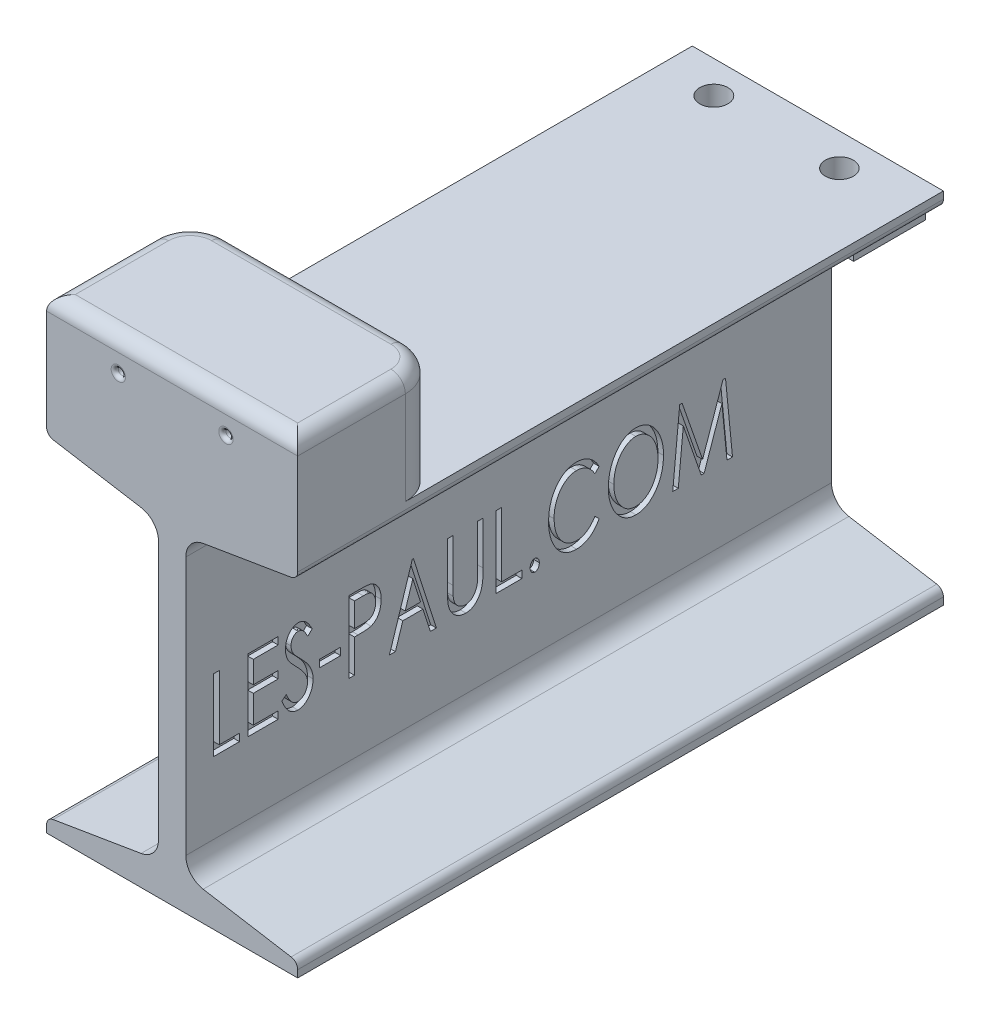
from build123d import *

# Parameters (mm, degrees)
BOSS_EXTRUDE1_DEPTH = 114.3
SKETCH2_W           = 88.9
SKETCH2_H           = 50.8
BOSS_EXTRUDE2_DEPTH = 38.1
FILLET4_R           = 12.7
FILLET5_R           = 5.08
SKETCH42_R          = 1.27
CUT_EXTRUDE3_DEPTH  = 88.9
FILLET8_R           = 1.27
SKETCH45_W          = 76.2
SKETCH45_H          = 25.4
BOSS_EXTRUDE3_DEPTH = 12.065
SKETCH47_R          = 5
CUT_EXTRUDE5_DEPTH  = 12.065
SKETCH47_4_R        = 5
SKETCH47_4_R_2      = 4.953
CUT_EXTRUDE9_DEPTH  = 25.4
SKETCH51_W          = 7.48974359
SKETCH51_H          = 2.605128205
CUT_EXTRUDE8_DEPTH  = 2
SKETCH52_R          = 1.905
CUT_EXTRUDE10_DEPTH = 8.89
SKETCH53_R          = 1.905
CUT_EXTRUDE11_DEPTH = 8.89


with BuildPart() as part:
    # Sketch1 → Boss-Extrude1 (new body, symmetric)
    with BuildSketch(Plane.XY):
        with BuildLine():
            Line((-44.45, 63.5), (44.45, 63.5))
            Line((44.45, 63.5), (44.45, 60.96))
            ThreePointArc((44.45, 60.96), (43.787841232, 59.153985338), (42.11521907, 58.203996762))
            Line((42.11521907, 58.203996762), (10.981331544, 53.016312413))
            ThreePointArc((10.981331544, 53.016312413), (6.571691296, 50.511797077), (4.826, 45.750485695))
            Line((4.826, 45.750485695), (4.826, -45.750485695))
            ThreePointArc((4.826, -45.750485695), (6.571691296, -50.511797077), (10.981331544, -53.016312413))
            Line((10.981331544, -53.016312413), (42.11521907, -58.203996762))
            ThreePointArc((42.11521907, -58.203996762), (43.787841232, -59.153985338), (44.45, -60.96))
            Line((44.45, -60.96), (44.45, -63.5))
            Line((44.45, -63.5), (-44.45, -63.5))
            Line((-44.45, -63.5), (-44.45, -60.96))
            ThreePointArc((-44.45, -60.96), (-43.787841232, -59.153985338), (-42.11521907, -58.203996762))
            Line((-42.11521907, -58.203996762), (-10.981331544, -53.016312413))
            ThreePointArc((-10.981331544, -53.016312413), (-6.571691296, -50.511797077), (-4.826, -45.750485695))
            Line((-4.826, -45.750485695), (-4.826, 45.750485695))
            ThreePointArc((-4.826, 45.750485695), (-6.571691296, 50.511797077), (-10.981331544, 53.016312413))
            Line((-10.981331544, 53.016312413), (-42.11521907, 58.203996762))
            ThreePointArc((-42.11521907, 58.203996762), (-43.787841232, 59.153985338), (-44.45, 60.96))
            Line((-44.45, 60.96), (-44.45, 63.5))
        make_face()
    extrude(amount=BOSS_EXTRUDE1_DEPTH, both=True)

    # Sketch2 → Boss-Extrude2 (add)
    with BuildSketch(Plane(origin=(0, 63.5, 0), x_dir=(1, 0, 0), z_dir=(0, 1, 0))):
        with Locations((0, -88.9)):
            Rectangle(SKETCH2_W, SKETCH2_H)
    extrude(amount=BOSS_EXTRUDE2_DEPTH)

    # Fillet4
    fillet4_edges = [part.edges().sort_by_distance(p)[0] for p in [
        (44.45, 82.55, 63.5),
        (-44.45, 82.55, 63.5),
    ]]
    fillet(fillet4_edges, radius=FILLET4_R)

    # Fillet5
    fillet5_edges = [part.edges().sort_by_distance(p)[0] for p in [
        (0, 101.6, 114.3),
        (44.45, 101.6, 95.25),
        (-44.45, 101.6, 95.25),
        (0, 101.6, 63.5),
        (40.730256121, 101.6, 67.219743879),
        (-40.730256121, 101.6, 67.219743879),
    ]]
    fillet(fillet5_edges, radius=FILLET5_R)

    # Sketch42 → Cut-Extrude3 (cut, symmetric)
    with BuildSketch(Plane(origin=(0, 141.271299333, 63.5), x_dir=(-1, 0, 0), z_dir=(0, 0, 1))):
        with Locations((19.05, 51.101299333)):
            Circle(SKETCH42_R)
        with Locations((-19.05, 51.101299333)):
            Circle(SKETCH42_R)
    extrude(amount=CUT_EXTRUDE3_DEPTH, both=True, mode=Mode.SUBTRACT)

    # Fillet8
    fillet8_edges = [part.edges().sort_by_distance(p)[0] for p in [
        (-17.78, 90.17, 114.3),
        (20.32, 90.17, 114.3),
    ]]
    fillet(fillet8_edges, radius=FILLET8_R)

    # Sketch45 → Boss-Extrude3 (add)
    with BuildSketch(Plane(origin=(0, 63.5, 0), x_dir=(1, 0, 0), z_dir=(0, 1, 0))):
        with Locations((0, 101.6)):
            Rectangle(SKETCH45_W, SKETCH45_H)
    extrude(amount=-BOSS_EXTRUDE3_DEPTH)

    # Sketch47 → Cut-Extrude5 (cut)
    with BuildSketch(Plane(origin=(0, 63.5, 0), x_dir=(1, 0, 0), z_dir=(0, 1, 0))):
        with Locations((-25.4, 102.87)):
            Circle(SKETCH47_R)
    extrude(amount=-CUT_EXTRUDE5_DEPTH, mode=Mode.SUBTRACT)

    # Sketch47_4 → Cut-Extrude9 (cut)
    with BuildSketch(Plane(origin=(0, 63.5, 0), x_dir=(1, 0, 0), z_dir=(0, 1, 0))):
        with Locations((-25.4, 102.87)):
            Circle(SKETCH47_4_R)
        with Locations((19.05, 102.87)):
            Circle(SKETCH47_4_R_2)
    extrude(amount=-CUT_EXTRUDE9_DEPTH, mode=Mode.SUBTRACT)

    # Sketch51 → Cut-Extrude8 (cut)
    with BuildSketch(Plane(origin=(4.826, 0, 0), x_dir=(0, 0, -1), z_dir=(1, 0, 0))):
        Polygon((-104.400512821, 5.049514305), (-102.446666667, 5.049514305), (-102.446666667, -17.74535749), (-95.282564103, -17.74535749), (-95.282564103, -20.350485695), (-104.400512821, -20.350485695), align=None)
        Polygon((-92.351794872, 5.049514305), (-81.605641026, 5.049514305), (-81.605641026, 2.444386099), (-90.397948718, 2.444386099), (-90.397948718, -5.370998516), (-81.605641026, -5.370998516), (-81.605641026, -7.976126721), (-90.397948718, -7.976126721), (-90.397948718, -17.74535749), (-81.605641026, -17.74535749), (-81.605641026, -20.350485695), (-92.351794872, -20.350485695), align=None)
        with BuildLine():
            Line((-80.303076923, -15.450605888), (-78.715576923, -14.163306208))
            add(Edge.make_bspline(
                [(-78.715576923, -14.163306208), (-78.574883617, -14.496433349), (-78.307790261, -15.128844713), (-77.848672791, -15.991031141), (-77.378359146, -16.725351333), (-76.890233935, -17.328288444), (-76.384195686, -17.804340451), (-75.85371575, -18.142323844), (-75.302010403, -18.357564561), (-74.923304676, -18.383738902), (-74.736650641, -18.396639542)],
                knots=[0, 0, 0, 0, 0.001084395, 0.002058624, 0.002926566, 0.003696626, 0.004380825, 0.005000535, 0.005575224, 0.006133762, 0.006133762, 0.006133762, 0.006133762], degree=3))
            add(Edge.make_bspline(
                [(-74.736650641, -18.396639542), (-74.576468371, -18.390537748), (-74.258840481, -18.378438407), (-73.793054903, -18.257490271), (-73.340345311, -18.0751798), (-72.912086788, -17.812424708), (-72.508521276, -17.497580365), (-72.163797993, -17.113149287), (-71.857485983, -16.690314469), (-71.617890012, -16.213746414), (-71.424733171, -15.708929022), (-71.290284342, -15.182736725), (-71.196220604, -14.643254704), (-71.188856966, -14.277354762), (-71.185128205, -14.092072234)],
                knots=[0, 0, 0, 0, 0.00047961, 0.000951025, 0.0014348, 0.001939168, 0.002453297, 0.002964649, 0.003482791, 0.004015298, 0.00455961, 0.005101396, 0.005642607, 0.006197798, 0.006197798, 0.006197798, 0.006197798], degree=3))
            add(Edge.make_bspline(
                [(-71.185128205, -14.092072234), (-71.193674346, -13.881298182), (-71.210894362, -13.456599726), (-71.329186502, -12.824261314), (-71.536991306, -12.200441646), (-71.7284779, -11.802193381), (-71.826233974, -11.598883131)],
                knots=[0, 0, 0, 0, 0.000632241, 0.001273932, 0.001922366, 0.002598649, 0.002598649, 0.002598649, 0.002598649], degree=3))
            add(Edge.make_bspline(
                [(-71.826233974, -11.598883131), (-71.905987395, -11.453745961), (-72.072088808, -11.151470663), (-72.365014851, -10.699407637), (-72.703227769, -10.225743541), (-73.082307628, -9.727923138), (-73.514212659, -9.213847701), (-73.986064705, -8.67474508), (-74.50542128, -8.114957594), (-74.873060772, -7.741135876), (-75.062291667, -7.548722875)],
                knots=[0, 0, 0, 0, 0.000496687, 0.001034444, 0.001614692, 0.002242599, 0.002911007, 0.003628507, 0.004391796, 0.005201386, 0.005201386, 0.005201386, 0.005201386], degree=3))
            add(Edge.make_bspline(
                [(-75.062291667, -7.548722875), (-75.25189093, -7.358349557), (-75.615101585, -6.993656065), (-76.114764574, -6.450539225), (-76.571044501, -5.961384157), (-76.963046142, -5.50541873), (-77.302697139, -5.095265609), (-77.593123878, -4.730360526), (-77.816296476, -4.39919465), (-77.941286482, -4.189343936), (-77.998149038, -4.093875118)],
                knots=[0, 0, 0, 0, 0.000805953, 0.001543944, 0.002213764, 0.002812567, 0.003347427, 0.003811537, 0.004210916, 0.004544257, 0.004544257, 0.004544257, 0.004544257], degree=3))
            add(Edge.make_bspline(
                [(-77.998149038, -4.093875118), (-78.152440258, -3.793914077), (-78.459797177, -3.196374555), (-78.769602487, -2.237298794), (-78.968261992, -1.244297894), (-78.989675656, -0.568765651), (-79.000512821, -0.226887939)],
                knots=[0, 0, 0, 0, 0.001010441, 0.002012857, 0.003012751, 0.004037288, 0.004037288, 0.004037288, 0.004037288], degree=3))
            add(Edge.make_bspline(
                [(-79.000512821, -0.226887939), (-78.994305521, 0.041496069), (-78.982070331, 0.570507014), (-78.866540242, 1.344372237), (-78.683628239, 2.082613124), (-78.431597929, 2.778052601), (-78.111011709, 3.420077948), (-77.733048162, 4.000243636), (-77.281030927, 4.497518939), (-76.786237033, 4.928531811), (-76.241173941, 5.265998963), (-75.672646448, 5.524795485), (-75.072713582, 5.668738171), (-74.66611162, 5.690078118), (-74.461891026, 5.700796356)],
                knots=[0, 0, 0, 0, 0.000804715, 0.001586171, 0.002341413, 0.003083462, 0.00380024, 0.004490317, 0.0051533, 0.005810045, 0.006452401, 0.007069767, 0.007676942, 0.008289635, 0.008289635, 0.008289635, 0.008289635], degree=3))
            add(Edge.make_bspline(
                [(-74.461891026, 5.700796356), (-74.243669026, 5.690417405), (-73.807046608, 5.669651019), (-73.16679994, 5.487783195), (-72.554594587, 5.190244396), (-72.066474848, 4.855743598), (-71.687451483, 4.520671185), (-71.390353168, 4.22049364), (-71.098610553, 3.864313062), (-70.790224847, 3.469964893), (-70.488913429, 3.019190023), (-70.175643019, 2.526339413), (-69.868642719, 1.979242308), (-69.663201287, 1.598355935), (-69.556923077, 1.401317189)],
                knots=[0, 0, 0, 0, 0.000653683, 0.0013079, 0.001979264, 0.002689165, 0.003074959, 0.003495924, 0.003954562, 0.004455273, 0.004997202, 0.005580232, 0.006206921, 0.006878575, 0.006878575, 0.006878575, 0.006878575], degree=3))
            Line((-69.556923077, 1.401317189), (-71.083365385, -0.160742106))
            add(Edge.make_bspline(
                [(-71.083365385, -0.160742106), (-71.168930099, -0.000795523), (-71.332993353, 0.305888801), (-71.584061842, 0.739264255), (-71.820916916, 1.13099335), (-72.05094068, 1.478357018), (-72.269429838, 1.784187514), (-72.477206685, 2.051494102), (-72.678614357, 2.273670301), (-72.927821762, 2.510573967), (-73.240715575, 2.74512807), (-73.639017921, 2.949431668), (-74.057957136, 3.071007308), (-74.34410618, 3.087442087), (-74.487331731, 3.095668151)],
                knots=[0, 0, 0, 0, 0.000544146, 0.001043354, 0.00150236, 0.001917254, 0.002292847, 0.00262978, 0.002932343, 0.003191489, 0.00366062, 0.004099794, 0.004528227, 0.004957565, 0.004957565, 0.004957565, 0.004957565], degree=3))
            add(Edge.make_bspline(
                [(-74.487331731, 3.095668151), (-74.66877358, 3.08647948), (-75.024186363, 3.068480486), (-75.525353653, 2.879242124), (-75.971187528, 2.578372594), (-76.352332198, 2.170810679), (-76.661269865, 1.680842351), (-76.88786195, 1.128659851), (-77.021007222, 0.520540979), (-77.037943899, 0.097723497), (-77.046666667, -0.120036977)],
                knots=[0, 0, 0, 0, 0.000542239, 0.001062152, 0.001582885, 0.002144336, 0.002723065, 0.003311731, 0.003926533, 0.004579423, 0.004579423, 0.004579423, 0.004579423], degree=3))
            add(Edge.make_bspline(
                [(-77.046666667, -0.120036977), (-77.033080223, -0.390714519), (-77.005922293, -0.93177164), (-76.843629942, -1.599403645), (-76.642627053, -2.129342179), (-76.428746008, -2.539066923), (-76.174599595, -2.971704269), (-75.972083393, -3.25420864), (-75.866217949, -3.401887939)],
                knots=[0, 0, 0, 0, 0.000811714, 0.001622534, 0.002047752, 0.002509681, 0.003007071, 0.003551883, 0.003551883, 0.003551883, 0.003551883], degree=3))
            add(Edge.make_bspline(
                [(-75.866217949, -3.401887939), (-75.827835439, -3.451600508), (-75.736576788, -3.569797627), (-75.560941685, -3.758140072), (-75.340211291, -4.003503553), (-75.062080868, -4.292129336), (-74.73700842, -4.63684926), (-74.352902659, -5.021190357), (-73.921179917, -5.459513004), (-73.615645978, -5.767953556), (-73.454439103, -5.930694029)],
                knots=[0, 0, 0, 0, 0.00018833, 0.000447775, 0.000771902, 0.001178604, 0.001650047, 0.002193335, 0.00280858, 0.00349578, 0.00349578, 0.00349578, 0.00349578], degree=3))
            add(Edge.make_bspline(
                [(-73.454439103, -5.930694029), (-73.260089637, -6.131578371), (-72.882087045, -6.522291058), (-72.346688869, -7.108486753), (-71.85668176, -7.67626187), (-71.420196394, -8.232054599), (-71.025925928, -8.766747429), (-70.678124786, -9.284447064), (-70.382162152, -9.78984777), (-70.053120761, -10.432908519), (-69.729533391, -11.231594932), (-69.438239942, -12.192390034), (-69.264617012, -13.159729922), (-69.242344243, -13.806472362), (-69.231282051, -14.127689221)],
                knots=[0, 0, 0, 0, 0.000838494, 0.00163084, 0.002381406, 0.003087852, 0.003750366, 0.004374115, 0.004957922, 0.005506333, 0.006540028, 0.007538134, 0.008514341, 0.009477627, 0.009477627, 0.009477627, 0.009477627], degree=3))
            add(Edge.make_bspline(
                [(-69.231282051, -14.127689221), (-69.236519066, -14.355134053), (-69.24686259, -14.804355837), (-69.318372907, -15.466447204), (-69.440192426, -16.10655258), (-69.61533976, -16.723270673), (-69.831914738, -17.320720737), (-70.103967282, -17.891392682), (-70.421218347, -18.439920118), (-70.782908222, -18.958188131), (-71.181645769, -19.433020967), (-71.603277765, -19.853472645), (-72.048074267, -20.207887604), (-72.516129622, -20.496855874), (-73.005716667, -20.72006243), (-73.515145392, -20.886632907), (-74.047579911, -20.98566503), (-74.4105984, -20.996359421), (-74.594182692, -21.001767747)],
                knots=[0, 0, 0, 0, 0.000682285, 0.001347568, 0.001995203, 0.002634712, 0.003268956, 0.003899414, 0.004528638, 0.005168066, 0.00579283, 0.006386488, 0.006951478, 0.007495148, 0.008032471, 0.008561858, 0.009099783, 0.009650149, 0.009650149, 0.009650149, 0.009650149], degree=3))
            add(Edge.make_bspline(
                [(-74.594182692, -21.001767747), (-74.736927008, -20.998188552), (-75.018662454, -20.99112427), (-75.435138458, -20.924549855), (-75.844486996, -20.832406731), (-76.240788092, -20.685131701), (-76.629712613, -20.509631519), (-77.003879286, -20.285724321), (-77.370555567, -20.026606371), (-77.728699096, -19.724355887), (-78.078039857, -19.374163986), (-78.417305558, -18.971863689), (-78.749091709, -18.515289114), (-79.072739215, -18.005828318), (-79.394201492, -17.444135858), (-79.70824748, -16.829511568), (-80.014319473, -16.160138837), (-80.204760855, -15.692187499), (-80.303076923, -15.450605888)],
                knots=[0, 0, 0, 0, 0.000427888, 0.000844526, 0.0012629, 0.001684571, 0.002110306, 0.002541389, 0.002990329, 0.003456137, 0.003945446, 0.004472505, 0.005033263, 0.005637361, 0.006282352, 0.006974133, 0.007707267, 0.008489667, 0.008489667, 0.008489667, 0.008489667], degree=3))
        make_face()
        with Locations((-63.206923077, -10.581254927)):
            Rectangle(SKETCH51_W, SKETCH51_H)
        with BuildLine():
            Line((-56.531282051, 5.049514305), (-52.898349359, 5.049514305))
            add(Edge.make_bspline(
                [(-52.898349359, 5.049514305), (-52.649010304, 5.049127554), (-52.170591209, 5.048385477), (-51.485311202, 5.026598822), (-50.862648149, 4.997311822), (-50.302851098, 4.95638716), (-49.80483673, 4.909355055), (-49.372443176, 4.841696449), (-49.001690845, 4.770874621), (-48.78154173, 4.700345007), (-48.680280449, 4.667903728)],
                knots=[0, 0, 0, 0, 0.000747974, 0.001435175, 0.002056678, 0.002617852, 0.003119079, 0.0035566, 0.003930812, 0.004249542, 0.004249542, 0.004249542, 0.004249542], degree=3))
            add(Edge.make_bspline(
                [(-48.680280449, 4.667903728), (-48.552015626, 4.619489914), (-48.295211071, 4.522558522), (-47.928952703, 4.332547841), (-47.581014099, 4.108071771), (-47.253706927, 3.845520441), (-46.942665308, 3.548980817), (-46.647057106, 3.218143743), (-46.371717984, 2.850158489), (-46.119477474, 2.447177817), (-45.883247624, 2.018502798), (-45.686874401, 1.554786194), (-45.512275649, 1.070077508), (-45.376565832, 0.553444781), (-45.263270829, 0.013938558), (-45.189048837, -0.555947186), (-45.142117935, -1.15043114), (-45.136639204, -1.556495486), (-45.133846154, -1.763506529)],
                knots=[0, 0, 0, 0, 0.000411007, 0.000822895, 0.001235003, 0.001651392, 0.002079674, 0.002522926, 0.002980859, 0.003456566, 0.003948329, 0.004447408, 0.0049656, 0.005492634, 0.006048454, 0.006618371, 0.007215442, 0.007836383, 0.007836383, 0.007836383, 0.007836383], degree=3))
            add(Edge.make_bspline(
                [(-45.133846154, -1.763506529), (-45.136423039, -1.972237292), (-45.141457617, -2.38004418), (-45.191116525, -2.977368426), (-45.256532579, -3.547823137), (-45.368349611, -4.088343611), (-45.49496568, -4.604263588), (-45.667577355, -5.088122819), (-45.857605826, -5.54782307), (-46.082766424, -5.975678602), (-46.332995003, -6.372297697), (-46.600873169, -6.741611214), (-46.897649176, -7.071856432), (-47.213815104, -7.371041177), (-47.55773514, -7.629204014), (-47.919543148, -7.861569976), (-48.307996904, -8.054695776), (-48.579300656, -8.158112609), (-48.715897436, -8.210181208)],
                knots=[0, 0, 0, 0, 0.000626027, 0.001223099, 0.001797405, 0.002347231, 0.002877887, 0.003389594, 0.003886671, 0.00436916, 0.00483785, 0.005292748, 0.005736, 0.006167983, 0.006596416, 0.007024122, 0.007456464, 0.007894872, 0.007894872, 0.007894872, 0.007894872], degree=3))
            add(Edge.make_bspline(
                [(-48.715897436, -8.210181208), (-48.82913221, -8.243939831), (-49.07534797, -8.317344004), (-49.483687297, -8.401072413), (-49.95596725, -8.470900541), (-50.496043926, -8.525366709), (-51.101804604, -8.569661071), (-51.775192385, -8.606051548), (-52.51322552, -8.625824368), (-53.027237781, -8.626865806), (-53.295224359, -8.627408772)],
                knots=[0, 0, 0, 0, 0.000354348, 0.000770488, 0.001249017, 0.001786196, 0.002398487, 0.003071066, 0.003809127, 0.004613069, 0.004613069, 0.004613069, 0.004613069], degree=3))
            Line((-53.295224359, -8.627408772), (-54.577435897, -8.627408772))
            Line((-54.577435897, -8.627408772), (-54.577435897, -20.350485695))
            Line((-54.577435897, -20.350485695), (-56.531282051, -20.350485695))
            Line((-56.531282051, -20.350485695), (-56.531282051, 5.049514305))
        make_face()
        with BuildLine():
            Line((-54.577435897, 2.444386099), (-54.577435897, -6.022280567))
            Line((-54.577435897, -6.022280567), (-51.570344551, -6.078250118))
            add(Edge.make_bspline(
                [(-51.570344551, -6.078250118), (-51.286835731, -6.07287522), (-50.75732528, -6.062836501), (-50.02432771, -5.978938482), (-49.408784403, -5.844701497), (-48.902832856, -5.636755027), (-48.486281899, -5.355830012), (-48.12896026, -5.005818034), (-47.819613843, -4.585188594), (-47.556903748, -4.099998762), (-47.344961094, -3.567366829), (-47.199301739, -2.994111282), (-47.104239547, -2.394219645), (-47.093265093, -1.982667415), (-47.087692308, -1.773682811)],
                knots=[0, 0, 0, 0, 0.000850268, 0.001588048, 0.002210072, 0.002734546, 0.003218588, 0.00370795, 0.004227962, 0.00477901, 0.005359148, 0.005942888, 0.006550234, 0.00717682, 0.00717682, 0.00717682, 0.00717682], degree=3))
            add(Edge.make_bspline(
                [(-47.087692308, -1.773682811), (-47.093294555, -1.569771147), (-47.104370282, -1.166634755), (-47.200069973, -0.577127952), (-47.34436422, -0.010121912), (-47.559264266, 0.516679765), (-47.811539713, 0.999318299), (-48.115349707, 1.412647557), (-48.45590874, 1.753512646), (-48.852959605, 2.022896919), (-49.33464404, 2.221342853), (-49.92646237, 2.348278921), (-50.639986668, 2.436475154), (-51.157863687, 2.441608684), (-51.438052885, 2.444386099)],
                knots=[0, 0, 0, 0, 0.00061134, 0.001208628, 0.001787447, 0.002362857, 0.00291148, 0.003417258, 0.003895787, 0.004350201, 0.004847279, 0.005448326, 0.006160847, 0.007000776, 0.007000776, 0.007000776, 0.007000776], degree=3))
            Line((-51.438052885, 2.444386099), (-54.577435897, 2.444386099))
        make_face(mode=Mode.SUBTRACT)
        Polygon((-33.736410256, 5.049514305), (-25.595384615, -20.350485695), (-27.722227564, -20.350485695), (-30.33244391, -12.209460054), (-37.466017628, -12.209460054), (-40.076233974, -20.350485695), (-42.203076923, -20.350485695), (-34.062051282, 5.049514305), align=None)
        Polygon((-33.90431891, -1.07660749), (-36.6315625, -9.604331849), (-31.166899038, -9.604331849), align=None, mode=Mode.SUBTRACT)
        with BuildLine():
            Line((-21.687692308, 5.049514305), (-19.733846154, 5.049514305))
            Line((-19.733846154, 5.049514305), (-19.733846154, -10.169115503))
            add(Edge.make_bspline(
                [(-19.733846154, -10.169115503), (-19.734419854, -10.384516578), (-19.73550855, -10.793277238), (-19.728236791, -11.374997759), (-19.725702189, -11.89235871), (-19.714004206, -12.346852391), (-19.704025682, -12.736958287), (-19.694984171, -13.064383663), (-19.682065003, -13.327637009), (-19.66489684, -13.481545667), (-19.657524038, -13.547641144)],
                knots=[0, 0, 0, 0, 0.000646194, 0.001226264, 0.00174528, 0.002198239, 0.002590158, 0.002915957, 0.003180981, 0.003380459, 0.003380459, 0.003380459, 0.003380459], degree=3))
            add(Edge.make_bspline(
                [(-19.657524038, -13.547641144), (-19.628500308, -13.785528724), (-19.572401982, -14.245328173), (-19.439416747, -14.902992696), (-19.247868487, -15.498207989), (-19.017901644, -16.041506813), (-18.713443662, -16.528228893), (-18.352378106, -16.976137824), (-17.910560553, -17.374210295), (-17.416863421, -17.729748591), (-16.884655689, -18.020840242), (-16.342600981, -18.238509636), (-15.795470228, -18.373915672), (-15.428316153, -18.389102605), (-15.246105769, -18.396639542)],
                knots=[0, 0, 0, 0, 0.00071887, 0.001389463, 0.002008985, 0.00259226, 0.003154263, 0.003725632, 0.004312624, 0.0049325, 0.005547303, 0.00612744, 0.006681581, 0.007227531, 0.007227531, 0.007227531, 0.007227531], degree=3))
            add(Edge.make_bspline(
                [(-15.246105769, -18.396639542), (-15.08962082, -18.389043265), (-14.77878863, -18.373954482), (-14.316590866, -18.274558358), (-13.869052874, -18.102389717), (-13.428355626, -17.875103887), (-13.017408151, -17.578544882), (-12.628794838, -17.238033747), (-12.290631999, -16.8342915), (-11.977105905, -16.390448523), (-11.700348353, -15.893297698), (-11.471044736, -15.34409019), (-11.272560598, -14.747796334), (-11.181788637, -14.328876041), (-11.134887821, -14.112424798)],
                knots=[0, 0, 0, 0, 0.000469462, 0.000932511, 0.001410715, 0.001904579, 0.002415627, 0.002927333, 0.003450522, 0.003991159, 0.004556035, 0.005153323, 0.005774409, 0.006438387, 0.006438387, 0.006438387, 0.006438387], degree=3))
            add(Edge.make_bspline(
                [(-11.134887821, -14.112424798), (-11.118829001, -14.022660899), (-11.082910338, -13.821886536), (-11.043103257, -13.485669778), (-11.017354938, -13.08635569), (-10.982523165, -12.625430568), (-10.966224461, -12.100974039), (-10.94844737, -11.512501877), (-10.947256666, -10.861088123), (-10.943500587, -10.406556715), (-10.941538462, -10.169115503)],
                knots=[0, 0, 0, 0, 0.000273532, 0.000611807, 0.001014928, 0.001473877, 0.001998351, 0.002588773, 0.003240074, 0.003952432, 0.003952432, 0.003952432, 0.003952432], degree=3))
            Line((-10.941538462, -10.169115503), (-10.941538462, 5.049514305))
            Line((-10.941538462, 5.049514305), (-8.987692308, 5.049514305))
            Line((-8.987692308, 5.049514305), (-8.987692308, -10.291230888))
            add(Edge.make_bspline(
                [(-8.987692308, -10.291230888), (-8.990533503, -10.567689397), (-8.996077146, -11.107105631), (-9.013427966, -11.897839266), (-9.055248583, -12.647631356), (-9.110508473, -13.356854675), (-9.18120725, -14.023757316), (-9.267674915, -14.651616557), (-9.368044959, -15.239108412), (-9.52083616, -15.961557271), (-9.776619791, -16.81273591), (-10.218639971, -17.768322022), (-10.79046292, -18.655096676), (-11.360184996, -19.331391117), (-11.873854095, -19.814309761), (-12.282598124, -20.131452442), (-12.709738156, -20.401659521), (-13.157032622, -20.625112237), (-13.626448525, -20.789923549), (-14.114452866, -20.915562923), (-14.623304788, -20.985867639), (-14.96945034, -20.996430688), (-15.144342949, -21.001767747)],
                knots=[0, 0, 0, 0, 0.000829429, 0.001618354, 0.002372498, 0.003081961, 0.003752303, 0.004384093, 0.004983026, 0.005539893, 0.006598936, 0.007641595, 0.008687452, 0.009755913, 0.010285105, 0.010800089, 0.011305457, 0.011799242, 0.012296554, 0.012795114, 0.013308891, 0.013833586, 0.013833586, 0.013833586, 0.013833586], degree=3))
            add(Edge.make_bspline(
                [(-15.144342949, -21.001767747), (-15.334444779, -20.996045068), (-15.708998608, -20.984769788), (-16.261665501, -20.920457578), (-16.789998131, -20.800724473), (-17.30120776, -20.644562733), (-17.787408934, -20.432366142), (-18.26038219, -20.186471825), (-18.702238532, -19.879117375), (-19.130351055, -19.542682642), (-19.525278722, -19.160658417), (-19.887265534, -18.745553018), (-20.220658136, -18.304732909), (-20.508203878, -17.827370218), (-20.770980402, -17.325568616), (-20.999288128, -16.793878471), (-21.18794843, -16.229645739), (-21.286497992, -15.841385898), (-21.336610577, -15.643955247)],
                knots=[0, 0, 0, 0, 0.000570439, 0.001123925, 0.001665878, 0.002193722, 0.002724866, 0.00325523, 0.003790091, 0.004336799, 0.004887378, 0.005435435, 0.005988008, 0.006543012, 0.00710513, 0.007686382, 0.008276892, 0.008887829, 0.008887829, 0.008887829, 0.008887829], degree=3))
            add(Edge.make_bspline(
                [(-21.336610577, -15.643955247), (-21.3651897, -15.508533148), (-21.427406906, -15.213717078), (-21.495101418, -14.729190151), (-21.554953912, -14.170876531), (-21.607119698, -13.538155706), (-21.63776502, -12.83201936), (-21.672113064, -12.0520219), (-21.684450758, -11.196956491), (-21.68658149, -10.60160589), (-21.687692308, -10.291230888)],
                knots=[0, 0, 0, 0, 0.000415112, 0.000903707, 0.001466723, 0.0020997, 0.002807848, 0.003586932, 0.004441876, 0.00537302, 0.00537302, 0.00537302, 0.00537302], degree=3))
            Line((-21.687692308, -10.291230888), (-21.687692308, 5.049514305))
        make_face()
        Polygon((-4.428717949, 5.049514305), (-2.474871795, 5.049514305), (-2.474871795, -17.74535749), (4.689230769, -17.74535749), (4.689230769, -20.350485695), (-4.428717949, -20.350485695), align=None)
        with BuildLine():
            add(Edge.make_bspline(
                [(9.248205128, -16.442793388), (9.357685185, -16.45117466), (9.574048565, -16.467738411), (9.885896937, -16.585144278), (10.164862871, -16.786744107), (10.410783294, -17.057131819), (10.615586159, -17.379584969), (10.773485392, -17.740423245), (10.858613205, -18.140026264), (10.870349325, -18.416618454), (10.876410256, -18.559460054)],
                knots=[0, 0, 0, 0, 0.000328175, 0.000648567, 0.000984538, 0.001351802, 0.001738534, 0.002126035, 0.002527257, 0.00295575, 0.00295575, 0.00295575, 0.00295575], degree=3))
            add(Edge.make_bspline(
                [(10.876410256, -18.559460054), (10.870120689, -18.698878826), (10.857798962, -18.972010482), (10.773741068, -19.368467348), (10.614115424, -19.72994497), (10.412429179, -20.055944852), (10.164886383, -20.327492872), (9.884788133, -20.527359019), (9.575215863, -20.652614995), (9.357873824, -20.668241658), (9.248205128, -20.676126721)],
                knots=[0, 0, 0, 0, 0.000418343, 0.000819565, 0.001207066, 0.001598092, 0.001965356, 0.002301327, 0.002623532, 0.002951707, 0.002951707, 0.002951707, 0.002951707], degree=3))
            add(Edge.make_bspline(
                [(9.248205128, -20.676126721), (9.138482352, -20.668317699), (8.921033137, -20.652841734), (8.610958156, -20.525920707), (8.326677342, -20.329449327), (8.079481459, -20.05551119), (7.875882643, -19.731263361), (7.724140643, -19.367124251), (7.638181975, -18.972195679), (7.626144482, -18.698941412), (7.62, -18.559460054)],
                knots=[0, 0, 0, 0, 0.000328175, 0.00065038, 0.000990525, 0.001357788, 0.001748815, 0.00213434, 0.002535562, 0.002953905, 0.002953905, 0.002953905, 0.002953905], degree=3))
            add(Edge.make_bspline(
                [(7.62, -18.559460054), (7.625910501, -18.416553565), (7.637355336, -18.139835727), (7.724396655, -17.741766412), (7.874436941, -17.378278185), (8.081123528, -17.057561776), (8.326698585, -16.784787628), (8.609836957, -16.586554169), (8.922199845, -16.467509752), (9.138670692, -16.451097833), (9.248205128, -16.442793388)],
                knots=[0, 0, 0, 0, 0.000428493, 0.000829715, 0.00121524, 0.001601972, 0.001969236, 0.002309381, 0.002629772, 0.002957947, 0.002957947, 0.002957947, 0.002957947], degree=3))
        make_face()
        with BuildLine():
            Line((32.043076923, 0.388777125), (30.567516026, -1.137665183))
            add(Edge.make_bspline(
                [(30.567516026, -1.137665183), (30.365599146, -0.80756093), (29.973387366, -0.166352643), (29.289404565, 0.696909986), (28.534807974, 1.424690638), (27.727701589, 2.030796204), (26.869652313, 2.509799174), (25.962076402, 2.847381147), (25.014302572, 3.059851564), (24.366179375, 3.083663483), (24.03943109, 3.095668151)],
                knots=[0, 0, 0, 0, 0.001160197, 0.002253614, 0.003293551, 0.004296935, 0.005273977, 0.006230385, 0.007193443, 0.008172602, 0.008172602, 0.008172602, 0.008172602], degree=3))
            add(Edge.make_bspline(
                [(24.03943109, 3.095668151), (23.859381578, 3.092656319), (23.499530748, 3.086636808), (22.967368351, 3.010199005), (22.44419207, 2.900246368), (21.932166349, 2.740122239), (21.43060983, 2.536862782), (20.935877473, 2.290688618), (20.456036098, 1.995283753), (19.986577396, 1.658773597), (19.537166616, 1.283478674), (19.108172471, 0.877651471), (18.711410848, 0.435159739), (18.333029608, -0.030338217), (17.987790284, -0.532392414), (17.664816104, -1.063186423), (17.372898976, -1.627463973), (17.101497705, -2.217201057), (16.864214277, -2.832999668), (16.654244686, -3.467431674), (16.48307755, -4.124432238), (16.333983839, -4.797465832), (16.221854133, -5.490617541), (16.149009463, -6.202633691), (16.0934915, -6.932191906), (16.088955538, -7.426497262), (16.086666667, -7.675926401)],
                knots=[0, 0, 0, 0, 0.000539727, 0.00107871, 0.001609635, 0.002142337, 0.002685625, 0.003231742, 0.003798082, 0.004374189, 0.004963118, 0.005553342, 0.006144093, 0.006744838, 0.007351758, 0.007970443, 0.008607681, 0.009256593, 0.009917072, 0.010586429, 0.011260295, 0.011952918, 0.012653901, 0.013365259, 0.014099715, 0.014847828, 0.014847828, 0.014847828, 0.014847828], degree=3))
            add(Edge.make_bspline(
                [(16.086666667, -7.675926401), (16.09312673, -8.051034849), (16.105781912, -8.785867484), (16.216229041, -9.863709261), (16.389472615, -10.894156547), (16.648950759, -11.875644747), (16.96592045, -12.813482556), (17.359258869, -13.705105036), (17.829326137, -14.544290306), (18.359779926, -15.330986027), (18.946503931, -16.045802891), (19.575661765, -16.675828143), (20.248892722, -17.204003087), (20.953774675, -17.641233133), (21.698789794, -17.981978884), (22.483032105, -18.218142388), (23.303922781, -18.374575872), (23.865698891, -18.389201962), (24.151370192, -18.396639542)],
                knots=[0, 0, 0, 0, 0.001125043, 0.002203945, 0.003247064, 0.004256569, 0.005246144, 0.006214296, 0.007175523, 0.008128107, 0.009057121, 0.0099458, 0.010793705, 0.011618376, 0.012428989, 0.013243378, 0.014070744, 0.014926778, 0.014926778, 0.014926778, 0.014926778], degree=3))
            add(Edge.make_bspline(
                [(24.151370192, -18.396639542), (24.466227146, -18.384325687), (25.0887927, -18.359977546), (25.999699959, -18.153047395), (26.869205667, -17.820016184), (27.696292964, -17.348169859), (28.484260262, -16.747065947), (29.228757213, -16.010927143), (29.935320498, -15.144986371), (30.351659593, -14.498490449), (30.567516026, -14.163306208)],
                knots=[0, 0, 0, 0, 0.000943627, 0.001865831, 0.002787136, 0.003728125, 0.004712191, 0.005752028, 0.006862188, 0.008057479, 0.008057479, 0.008057479, 0.008057479], degree=3))
            Line((30.567516026, -14.163306208), (32.043076923, -15.674484093))
            add(Edge.make_bspline(
                [(32.043076923, -15.674484093), (31.928279739, -15.881010584), (31.700778277, -16.290298311), (31.325270159, -16.87316548), (30.926249659, -17.417584409), (30.51321479, -17.932972787), (30.072467841, -18.406845812), (29.612439519, -18.847360002), (29.132781, -19.252004831), (28.630321206, -19.616185702), (28.111866517, -19.944096928), (27.574723902, -20.223954784), (27.023910946, -20.463848618), (26.458376028, -20.663719749), (25.876358804, -20.817071718), (25.278784812, -20.921648818), (24.666945529, -20.991814844), (24.253331095, -20.998428742), (24.044519231, -21.001767747)],
                knots=[0, 0, 0, 0, 0.000708733, 0.001404544, 0.002078276, 0.002733067, 0.003384766, 0.004018153, 0.004642918, 0.005265773, 0.005878467, 0.006481578, 0.007080878, 0.007679508, 0.008279305, 0.00888413, 0.00949828, 0.010124452, 0.010124452, 0.010124452, 0.010124452], degree=3))
            add(Edge.make_bspline(
                [(24.044519231, -21.001767747), (23.847613776, -20.999803698), (23.456364011, -20.995901146), (22.879120272, -20.935248504), (22.315938594, -20.851797997), (21.771404979, -20.726739109), (21.238748279, -20.577698535), (20.726114791, -20.380294858), (20.225720218, -20.159421041), (19.744658149, -19.895690147), (19.276484963, -19.601309818), (18.823004282, -19.271223748), (18.391200477, -18.901922581), (17.971538322, -18.504506078), (17.569419127, -18.070602846), (17.182761871, -17.601295417), (16.809830393, -17.097393117), (16.57996917, -16.740923554), (16.463189103, -16.559820631)],
                knots=[0, 0, 0, 0, 0.000590422, 0.001173164, 0.001739504, 0.002297462, 0.002848205, 0.003397276, 0.003943867, 0.004488013, 0.005041381, 0.00560214, 0.006168937, 0.006744774, 0.007335218, 0.007942393, 0.008568255, 0.009214589, 0.009214589, 0.009214589, 0.009214589], degree=3))
            add(Edge.make_bspline(
                [(16.463189103, -16.559820631), (16.27627419, -16.242166507), (15.900316683, -15.603242348), (15.432488669, -14.585795333), (15.025385857, -13.524965966), (14.705531584, -12.411728607), (14.439152091, -11.254688265), (14.269876825, -10.045746303), (14.150207125, -8.790937299), (14.138685626, -7.937419698), (14.132820513, -7.502929606)],
                knots=[0, 0, 0, 0, 0.001105076, 0.002222731, 0.003354828, 0.004510855, 0.005694655, 0.006913623, 0.008170301, 0.009473352, 0.009473352, 0.009473352, 0.009473352], degree=3))
            add(Edge.make_bspline(
                [(14.132820513, -7.502929606), (14.141589467, -7.046347891), (14.158806664, -6.149883204), (14.294952637, -4.833994598), (14.509287804, -3.572397878), (14.823670189, -2.369577442), (15.21198823, -1.215613798), (15.703593574, -0.123575767), (16.275469348, 0.918396351), (16.932370598, 1.891514387), (17.651322115, 2.783172241), (18.426795818, 3.564062402), (19.25281889, 4.218535948), (20.115619598, 4.76605291), (21.029310418, 5.187414811), (21.989536999, 5.48187342), (22.992730951, 5.665876389), (23.677383821, 5.689055784), (24.024166667, 5.700796356)],
                knots=[0, 0, 0, 0, 0.001369476, 0.002688865, 0.003964538, 0.005204803, 0.006414819, 0.007612868, 0.008792538, 0.009976545, 0.011130387, 0.012224136, 0.013270674, 0.014285717, 0.015282888, 0.016279086, 0.017292137, 0.018331912, 0.018331912, 0.018331912, 0.018331912], degree=3))
            add(Edge.make_bspline(
                [(24.024166667, 5.700796356), (24.234638082, 5.697223633), (24.653250253, 5.690117749), (25.272644638, 5.622903738), (25.877366935, 5.509006911), (26.465902307, 5.357271412), (27.041246716, 5.165045608), (27.595093377, 4.91745162), (28.135816837, 4.632220346), (28.660480788, 4.307063277), (29.163379151, 3.938863217), (29.648103206, 3.538265325), (30.104531089, 3.097279695), (30.546700996, 2.629866203), (30.955607362, 2.11987507), (31.345407454, 1.576926044), (31.711051889, 0.999363428), (31.931698482, 0.593599485), (32.043076923, 0.388777125)],
                knots=[0, 0, 0, 0, 0.000631258, 0.001255525, 0.001866272, 0.002475915, 0.003077694, 0.003683696, 0.004293679, 0.004910688, 0.005533544, 0.006162212, 0.006795599, 0.007436382, 0.008091172, 0.008754819, 0.009440869, 0.010140169, 0.010140169, 0.010140169, 0.010140169], degree=3))
        make_face()
        with BuildLine():
            add(Edge.make_bspline(
                [(44.946602564, 5.700796356), (45.291614187, 5.68887377), (45.971080431, 5.665393418), (46.969763854, 5.484499457), (47.920366967, 5.173072776), (48.836226709, 4.757116187), (49.698622399, 4.204337883), (50.519011112, 3.53639389), (51.294213608, 2.745987933), (52.018379691, 1.845829141), (52.679457006, 0.862124893), (53.258774379, -0.188238529), (53.745369137, -1.294441702), (54.151237682, -2.455362465), (54.459688317, -3.673100149), (54.676629273, -4.947506169), (54.81159312, -6.275476793), (54.829066804, -7.180356814), (54.837948718, -7.640309413)],
                knots=[0, 0, 0, 0, 0.001034696, 0.002037731, 0.003032147, 0.004029319, 0.005047074, 0.006096021, 0.007196989, 0.00836194, 0.009557231, 0.010748269, 0.011955618, 0.013178572, 0.014433622, 0.015719322, 0.0170539, 0.018433546, 0.018433546, 0.018433546, 0.018433546], degree=3))
            add(Edge.make_bspline(
                [(54.837948718, -7.640309413), (54.829097108, -8.096877511), (54.811684899, -8.995003276), (54.676159649, -10.314418734), (54.459946723, -11.582192844), (54.149642932, -12.797655249), (53.745702696, -13.958363429), (53.26220502, -15.070064986), (52.686173865, -16.126622287), (52.023175386, -17.114549345), (51.305018396, -18.020095341), (50.537778617, -18.815688482), (49.733881399, -19.4951073), (48.880326886, -20.043062725), (47.992330094, -20.477455272), (47.059730262, -20.77639654), (46.092499221, -20.968045054), (45.432576696, -20.990450602), (45.099246795, -21.001767747)],
                knots=[0, 0, 0, 0, 0.001369476, 0.002693928, 0.003974614, 0.005224734, 0.006452495, 0.007657794, 0.008857754, 0.010057272, 0.011223001, 0.012320495, 0.013368059, 0.014372951, 0.015356056, 0.016324702, 0.01730365, 0.018302793, 0.018302793, 0.018302793, 0.018302793], degree=3))
            add(Edge.make_bspline(
                [(45.099246795, -21.001767747), (44.760817057, -20.99065685), (44.094110783, -20.968768393), (43.116895623, -20.775889074), (42.178494071, -20.477410331), (41.281185768, -20.049498493), (40.425739194, -19.499752187), (39.613248006, -18.824886132), (38.839092186, -18.033856907), (38.119521141, -17.129819648), (37.457440744, -16.14815482), (36.880494668, -15.098374762), (36.390923374, -13.999093129), (35.996077243, -12.846714275), (35.675252116, -11.649535669), (35.462302543, -10.397380341), (35.325500754, -9.096869126), (35.308255714, -8.212233088), (35.299487179, -7.762424798)],
                knots=[0, 0, 0, 0, 0.001014379, 0.001998326, 0.002976653, 0.003962151, 0.004971323, 0.006019554, 0.00712415, 0.008285907, 0.009481198, 0.010672236, 0.011874933, 0.013086606, 0.014323233, 0.015588882, 0.016893085, 0.01824222, 0.01824222, 0.01824222, 0.01824222], degree=3))
            add(Edge.make_bspline(
                [(35.299487179, -7.762424798), (35.303327996, -7.460422239), (35.310952809, -6.860884938), (35.374161426, -5.969503474), (35.474640285, -5.093181076), (35.618980639, -4.234684177), (35.793645946, -3.390774728), (36.022164637, -2.567573318), (36.276493064, -1.756225708), (36.586424045, -0.971783806), (36.914596162, -0.20992089), (37.290104558, 0.507054367), (37.685083734, 1.184391571), (38.108170299, 1.820874114), (38.56771407, 2.409301802), (39.051483321, 2.961858068), (39.564883641, 3.472416626), (40.110302289, 3.932982677), (40.669706127, 4.351225591), (41.249415792, 4.707025257), (41.83540877, 5.016837512), (42.43579699, 5.264297099), (43.046053709, 5.461838477), (43.6700959, 5.596250353), (44.304422161, 5.68883286), (44.732571588, 5.696809067), (44.946602564, 5.700796356)],
                knots=[0, 0, 0, 0, 0.000905918, 0.001798433, 0.00267949, 0.003551108, 0.004409331, 0.005263473, 0.006113086, 0.006958774, 0.007792608, 0.008600486, 0.009385001, 0.010144225, 0.010891264, 0.011623126, 0.012346305, 0.013061003, 0.013763185, 0.014439525, 0.015099514, 0.015749622, 0.016385232, 0.017021006, 0.017662878, 0.018304489, 0.018304489, 0.018304489, 0.018304489], degree=3))
        make_face()
        with BuildLine():
            add(Edge.make_bspline(
                [(45.033100962, 3.095668151), (44.863213373, 3.092660404), (44.523599407, 3.086647764), (44.020221721, 3.009863198), (43.522780641, 2.899031914), (43.031150827, 2.741308348), (42.548939561, 2.528825444), (42.068801231, 2.281283675), (41.598944798, 1.982808482), (41.139887253, 1.642628149), (40.691469298, 1.270370936), (40.275309059, 0.85320694), (39.87708564, 0.411848387), (39.505432354, -0.062889552), (39.159122436, -0.567784648), (38.836848516, -1.104138981), (38.543196056, -1.674368536), (38.182734206, -2.477075486), (37.806158396, -3.539265), (37.489260009, -4.881857814), (37.29020473, -6.29450146), (37.265790987, -7.259722884), (37.253333333, -7.752248516)],
                knots=[0, 0, 0, 0, 0.000509221, 0.001017959, 0.001524043, 0.002037341, 0.00256381, 0.003103177, 0.003656546, 0.004231528, 0.004816554, 0.005403016, 0.005997545, 0.006599109, 0.007210215, 0.007833258, 0.00847501, 0.009133192, 0.010472137, 0.011848176, 0.01326575, 0.014742793, 0.014742793, 0.014742793, 0.014742793], degree=3))
            add(Edge.make_bspline(
                [(37.253333333, -7.752248516), (37.259902859, -8.118863478), (37.272797174, -8.838435839), (37.382139528, -9.89452364), (37.559166636, -10.906689603), (37.808768105, -11.876648843), (38.128764246, -12.804745895), (38.521402151, -13.688658051), (38.987492917, -14.527256202), (39.516529278, -15.313958646), (40.095436173, -16.032637821), (40.712439645, -16.661457152), (41.356022133, -17.197996933), (42.033644838, -17.633025416), (42.738307257, -17.981020823), (43.479668548, -18.217174828), (44.246324637, -18.373776692), (44.769436385, -18.388977741), (45.033100962, -18.396639542)],
                knots=[0, 0, 0, 0, 0.001099615, 0.002158267, 0.003181337, 0.004179716, 0.005159668, 0.006123169, 0.007077477, 0.008034278, 0.008964017, 0.009841924, 0.010673208, 0.011472046, 0.012252591, 0.013023323, 0.013800677, 0.014590667, 0.014590667, 0.014590667, 0.014590667], degree=3))
            add(Edge.make_bspline(
                [(45.033100962, -18.396639542), (45.211409447, -18.393256628), (45.564206478, -18.386563273), (46.088483005, -18.316735514), (46.601539312, -18.206951651), (47.103921607, -18.045345419), (47.597085101, -17.846764868), (48.084219676, -17.610057753), (48.551440551, -17.313051771), (49.014739607, -16.987399059), (49.453870072, -16.612888356), (49.879729691, -16.214312079), (50.269267502, -15.771330826), (50.643127292, -15.306286727), (50.983725914, -14.801771546), (51.305443386, -14.270555283), (51.594339248, -13.700418148), (51.956352831, -12.899150483), (52.327088922, -11.834778814), (52.65708521, -10.496914209), (52.844885515, -9.087277333), (52.870849806, -8.125919785), (52.884102564, -7.635221272)],
                knots=[0, 0, 0, 0, 0.000534642, 0.001057831, 0.001583783, 0.002106774, 0.002638722, 0.003178017, 0.003728689, 0.004297697, 0.004875554, 0.005458585, 0.006045929, 0.006643499, 0.007247532, 0.007870575, 0.008505472, 0.009163654, 0.010507396, 0.011879685, 0.013291532, 0.014763492, 0.014763492, 0.014763492, 0.014763492], degree=3))
            add(Edge.make_bspline(
                [(52.884102564, -7.635221272), (52.881828146, -7.389181185), (52.877321328, -6.901646441), (52.821484585, -6.180599317), (52.748959223, -5.475322769), (52.636992944, -4.788934192), (52.488560919, -4.121977338), (52.310057862, -3.473305034), (52.100952885, -2.841665826), (51.863950773, -2.227494382), (51.594250402, -1.638556845), (51.299254292, -1.0776361), (50.978484154, -0.547220368), (50.631724829, -0.04773233), (50.260344359, 0.423679207), (49.856901526, 0.858526175), (49.434113327, 1.270510783), (48.982398466, 1.64289512), (48.518040223, 1.982860913), (48.043137202, 2.281404409), (47.557870574, 2.528767354), (47.069246675, 2.742411586), (46.568702601, 2.898990132), (46.06280044, 3.00934233), (45.551085571, 3.086966861), (45.206386728, 3.092757235), (45.033100962, 3.095668151)],
                knots=[0, 0, 0, 0, 0.000737938, 0.001462244, 0.002168543, 0.002864503, 0.003547187, 0.004217471, 0.004881995, 0.005542474, 0.006191386, 0.006824119, 0.007442804, 0.008049724, 0.008647293, 0.009241474, 0.009828024, 0.010416953, 0.010996041, 0.011553721, 0.012097605, 0.012628749, 0.01315174, 0.013667753, 0.01418153, 0.014700919, 0.014700919, 0.014700919, 0.014700919], degree=3))
        make_face(mode=Mode.SUBTRACT)
        Polygon((58.094358974, -20.350485695), (60.567195513, 5.049514305), (61.422003205, 5.049514305), (68.677692308, -15.791511336), (75.902852564, 5.049514305), (76.778012821, 5.049514305), (79.261025641, -20.350485695), (77.302091346, -20.350485695), (75.516153846, -2.114588259), (69.191594551, -20.350485695), (68.184142628, -20.350485695), (61.839230769, -2.114588259), (60.063469551, -20.350485695), align=None)
    extrude(amount=-CUT_EXTRUDE8_DEPTH, mode=Mode.SUBTRACT)

    # Sketch52 → Cut-Extrude10 (cut)
    with BuildSketch(Plane.XZ.offset(-51.435)):
        with Locations((31.242, -102.87)):
            Circle(SKETCH52_R)
    extrude(amount=-CUT_EXTRUDE10_DEPTH, mode=Mode.SUBTRACT)

    # Sketch53 → Cut-Extrude11 (cut)
    with BuildSketch(Plane.XZ.offset(-51.435)):
        with Locations((-13.208, -102.87)):
            Circle(SKETCH53_R)
    extrude(amount=-CUT_EXTRUDE11_DEPTH, mode=Mode.SUBTRACT)


solid = part.part
